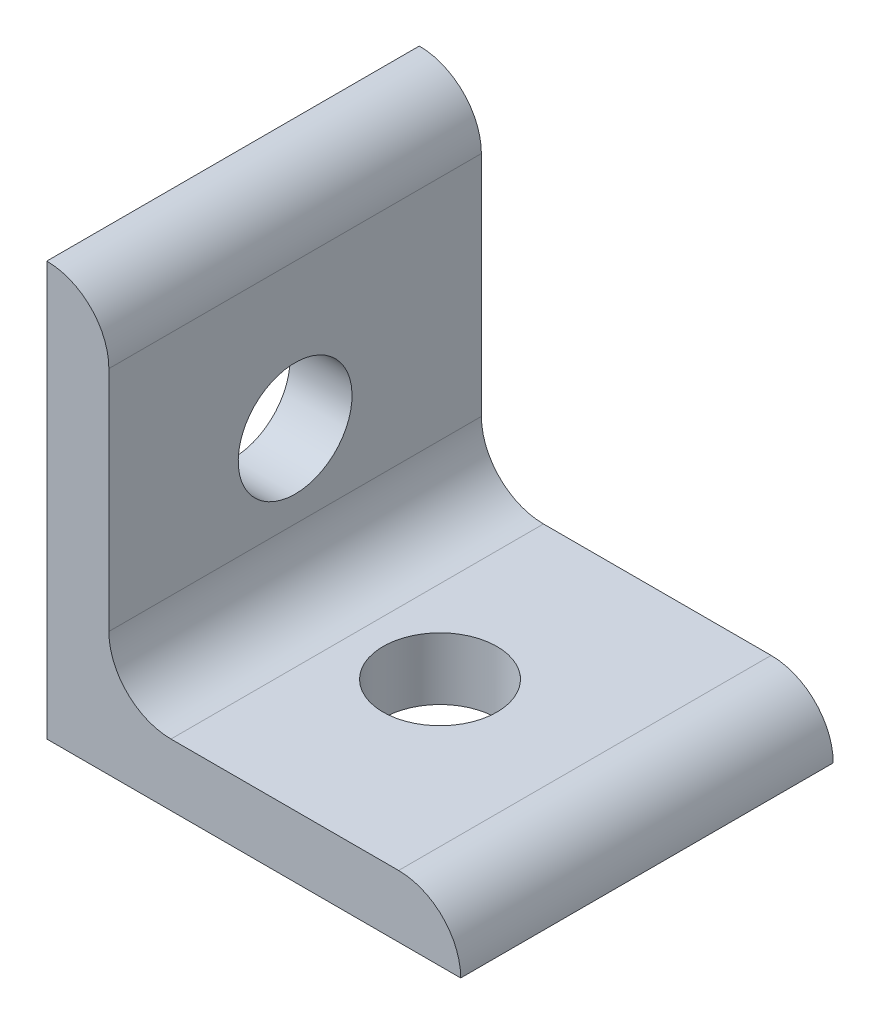
from build123d import *

# Parameters (mm, degrees)
BOSS_EXTRUDE1_DEPTH = 9
SKETCH2_R           = 2.75
CUT_EXTRUDE1_DEPTH  = 21
SKETCH3_R           = 2.75
CUT_EXTRUDE2_DEPTH  = 21


with BuildPart() as part:
    # Sketch1 → Boss-Extrude1 (new body, symmetric)
    with BuildSketch(Plane.XY):
        with BuildLine():
            Line((0, 0), (0, 20))
            ThreePointArc((0, 20), (2.121320344, 19.121320344), (3, 17))
            Line((3, 17), (3, 6))
            ThreePointArc((3, 6), (3.878679656, 3.878679656), (6, 3))
            Line((6, 3), (17, 3))
            ThreePointArc((17, 3), (19.121320344, 2.121320344), (20, 0))
            Line((20, 0), (0, 0))
        make_face()
    extrude(amount=BOSS_EXTRUDE1_DEPTH, both=True)

    # Sketch2 → Cut-Extrude1 (cut, through all)
    with BuildSketch(Plane(origin=(0, 0, 0), x_dir=(1, 0, 0), z_dir=(0, 1, 0))):
        with Locations((10, 0)):
            Circle(SKETCH2_R)
    extrude(amount=CUT_EXTRUDE1_DEPTH, mode=Mode.SUBTRACT)

    # Sketch3 → Cut-Extrude2 (cut, through all)
    with BuildSketch(Plane(origin=(0, 0, 0), x_dir=(0, 0, -1), z_dir=(1, 0, 0))):
        with Locations((0, 10)):
            Circle(SKETCH3_R)
    extrude(amount=CUT_EXTRUDE2_DEPTH, mode=Mode.SUBTRACT)


solid = part.part
